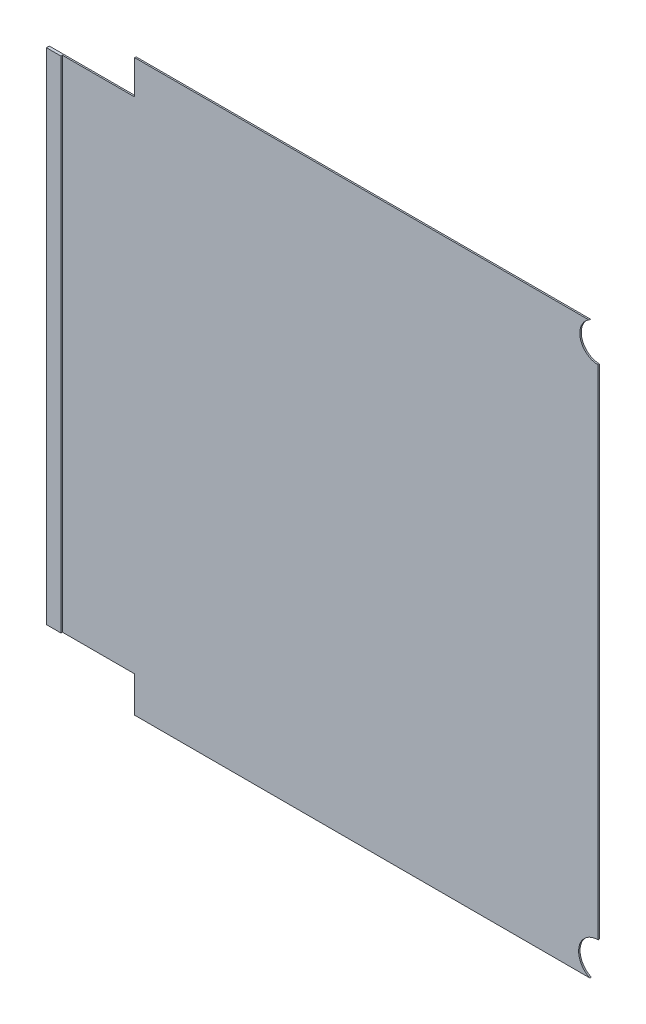
from build123d import *

# Parameters (mm, degrees)
DODANIE_WYCI_GNI_CIE1_DEPTH = 1
SZKIC2_W                    = 10
SZKIC2_H                    = 345
DODANIE_WYCI_GNI_CIE2_DEPTH = 2


with BuildPart() as part:
    # Szkic1 → Dodanie-wyciągnięcie1 (new body)
    with BuildSketch(Plane.XY):
        with BuildLine():
            Line((-286.27862804, 196), (-599.968042624, 196))
            Line((-599.968042624, 196), (-599.968042624, 172.5))
            Line((-599.968042624, 172.5), (-649.968042624, 172.5))
            Line((-649.968042624, 172.5), (-649.968042624, -172.5))
            Line((-649.968042624, -172.5), (-599.968042624, -172.5))
            Line((-599.968042624, -172.5), (-599.968042624, -197.196347915))
            Line((-599.968042624, -197.196347915), (-285.747034082, -197.196347915))
            ThreePointArc((-285.747034082, -197.196347915), (-293.157074923, -182.055397704), (-280, -171.517444485))
            Line((-280, -171.517444485), (-280, 172.334252092))
            ThreePointArc((-280, 172.334252092), (-292.242230129, 181.752081969), (-286.27862804, 196))
        make_face()
    extrude(amount=DODANIE_WYCI_GNI_CIE1_DEPTH)

    # Szkic2 → Dodanie-wyciągnięcie2 (add)
    with BuildSketch(Plane(origin=(0, 0, 0), x_dir=(-1, 0, 0), z_dir=(0, 0, -1))):
        with Locations((654.968042624, 0)):
            Rectangle(SZKIC2_W, SZKIC2_H)
    extrude(amount=-DODANIE_WYCI_GNI_CIE2_DEPTH)


solid = part.part
